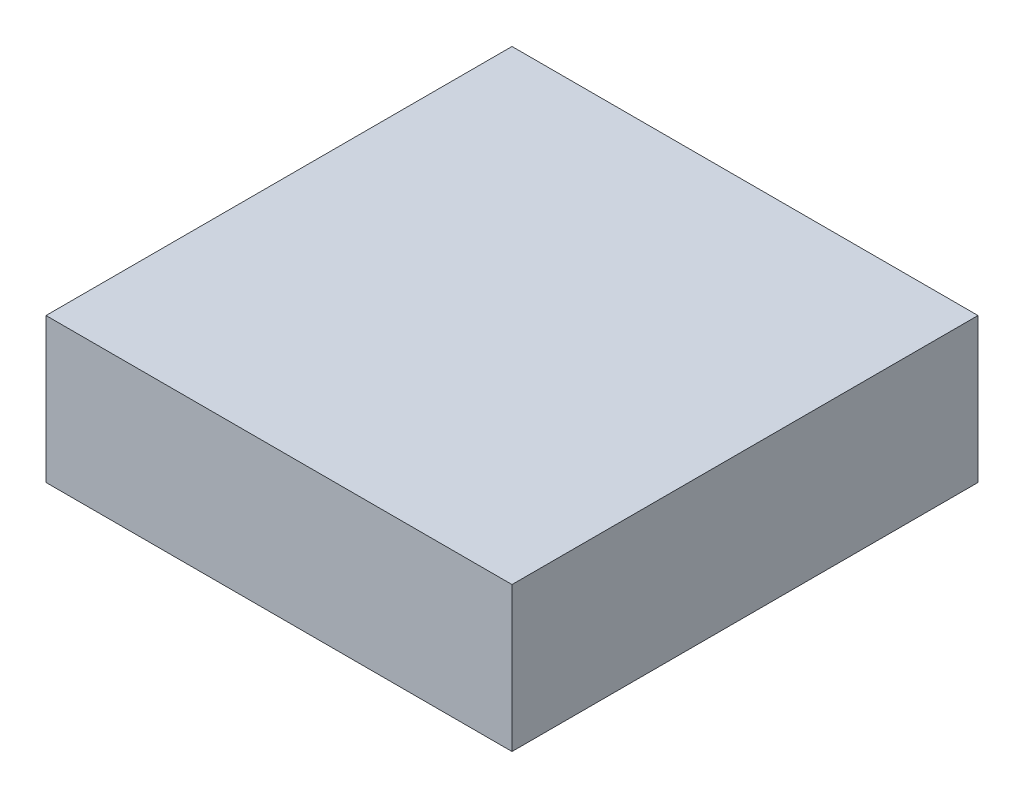
from build123d import *

# Parameters (mm, degrees)
SKETCH1_W           = 145
SKETCH1_H           = 145
BOSS_EXTRUDE1_DEPTH = 45


with BuildPart() as part:
    # Sketch1 → Boss-Extrude1 (new body)
    with BuildSketch(Plane(origin=(0, 0, 0), x_dir=(1, 0, 0), z_dir=(0, 1, 0))):
        Rectangle(SKETCH1_W, SKETCH1_H)
    extrude(amount=BOSS_EXTRUDE1_DEPTH)


solid = part.part
